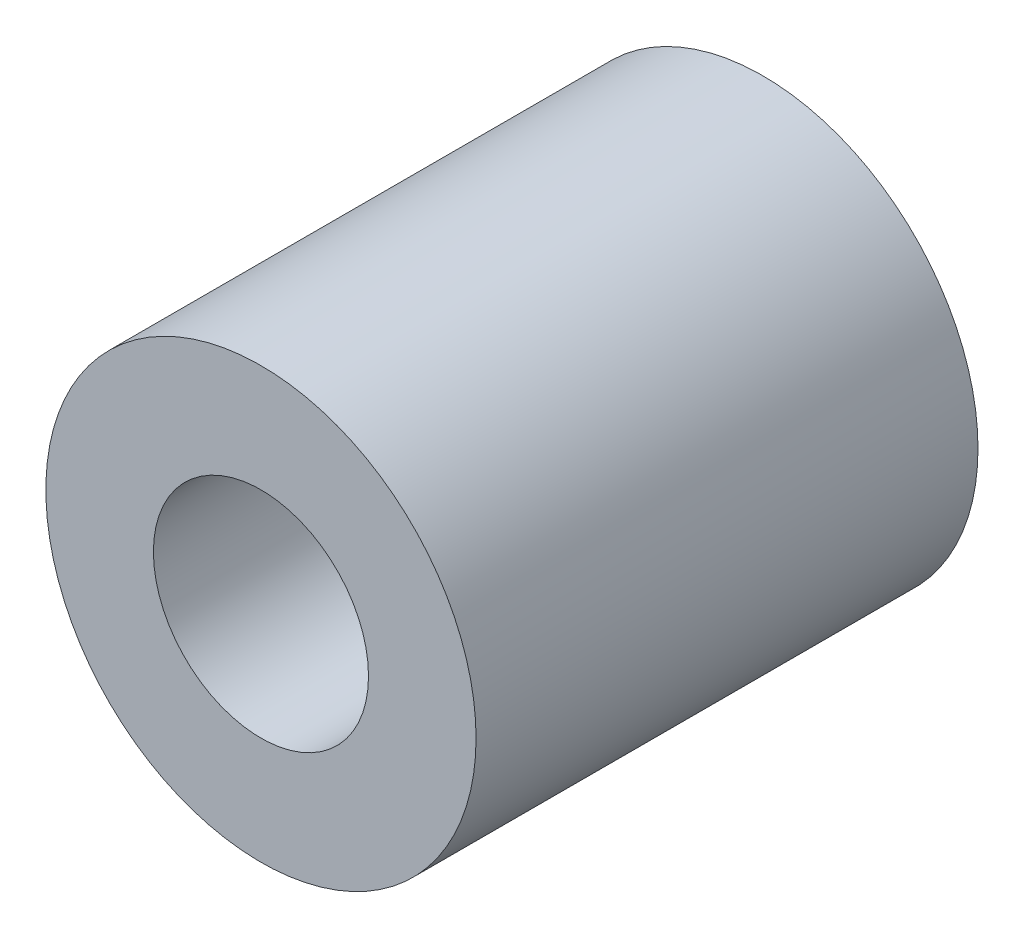
from build123d import *

# Parameters (mm, degrees)
SKETCH1_R           = 15
SKETCH1_R_2         = 6
BOSS_EXTRUDE1_DEPTH = 35
SKETCH2_R           = 7.5
CUT_EXTRUDE1_DEPTH  = 17.5


with BuildPart() as part:
    # Sketch1 → Boss-Extrude1 (new body)
    with BuildSketch(Plane.XY):
        Circle(SKETCH1_R)
        Circle(SKETCH1_R_2, mode=Mode.SUBTRACT)
    extrude(amount=BOSS_EXTRUDE1_DEPTH)

    # Sketch2 → Cut-Extrude1 (cut, symmetric)
    with BuildSketch(Plane.XY.offset(35)):
        Circle(SKETCH2_R)
    extrude(amount=CUT_EXTRUDE1_DEPTH, both=True, mode=Mode.SUBTRACT)


solid = part.part
